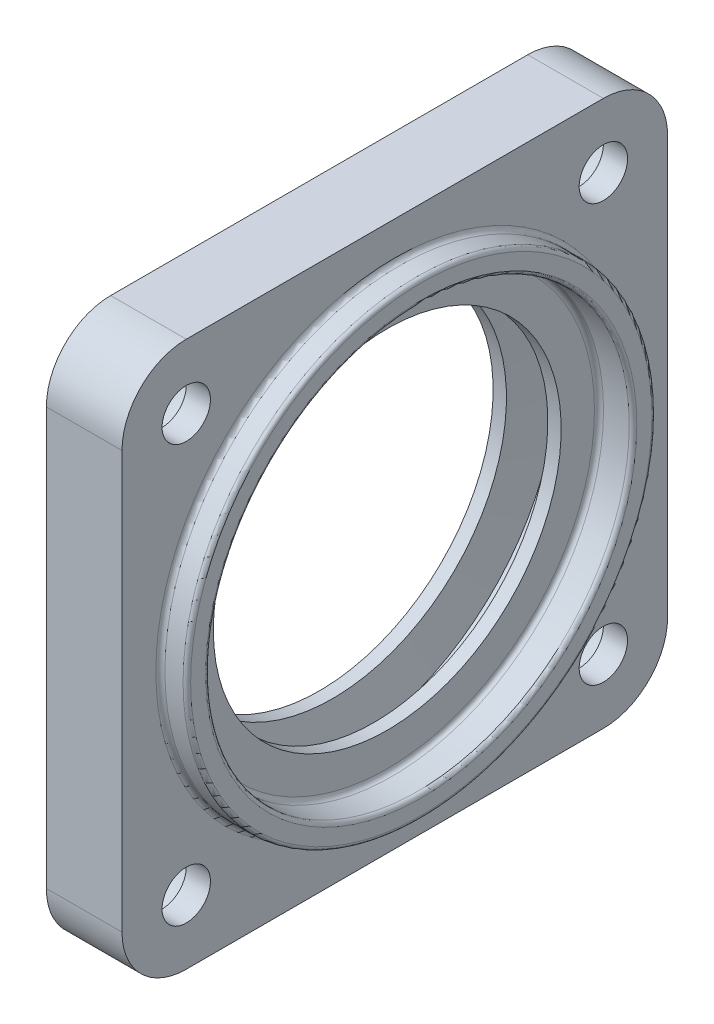
from build123d import *

# Parameters (mm, degrees)
HOLE_WIZARD_M61_D           = 6.4
HOLE_WIZARD_M61_CBORE_D     = 11
HOLE_WIZARD_M61_CBORE_DEPTH = 6.8
SKETCH_4_OUTSIDE_W          = 124.038
SKETCH_4_OUTSIDE_H          = 124.038
CUT_EXTRUDE_1_DEPTH         = 16
SKETCH_5_R                  = 31
CUT_EXTRUDE_2_DEPTH         = 1.5
FILLET_1_R                  = 0.6
FILLET_2_R                  = 0.5
FILLET_3_R                  = 0.6


with BuildPart() as part:
    # Эскиз1 → Повернуть1 (revolve)
    with BuildSketch(Plane.XY):
        Polygon((-4.5, 23), (-2.736707365, 23), (-2, 29), (2, 29), (2.736707365, 23), (4.5, 23), (4.5, 28), (10.5, 28), (10.5, 31), (5.5, 31), (5.5, 47.5), (-4.5, 47.5), align=None)
    revolve(axis=Axis((0, 0, 0), (1, 0, 0)))

    # Цековка для  болта с шестигранной головкой M61 (through all)
    with Locations(Plane(origin=(-4.5, 27.577164466, -27.577164466), x_dir=(0, 0, -1), z_dir=(-1, 0, 0))):
        with Locations((0, 0), (-55.154328932, 0), (-55.154328932, 55.154328932), (0, 55.154328932)):
            CounterBoreHole(HOLE_WIZARD_M61_D / 2, HOLE_WIZARD_M61_CBORE_D / 2, HOLE_WIZARD_M61_CBORE_DEPTH)

    # Эскиз4 outside → Вытянуть1 (cut, through all)
    with BuildSketch(Plane.ZY.offset(4.5)):
        Rectangle(SKETCH_4_OUTSIDE_W, SKETCH_4_OUTSIDE_H)
        with BuildLine():
            Line((-36.077164466, 27.577164466), (-36.077164466, -27.577164466))
            ThreePointArc((-36.077164466, -27.577164466), (-33.587572106, -33.587572106), (-27.577164466, -36.077164466))
            Line((-27.577164466, -36.077164466), (27.577164466, -36.077164466))
            ThreePointArc((27.577164466, -36.077164466), (33.587572106, -33.587572106), (36.077164466, -27.577164466))
            Line((36.077164466, -27.577164466), (36.077164466, 27.577164466))
            ThreePointArc((36.077164466, 27.577164466), (33.587572106, 33.587572106), (27.577164466, 36.077164466))
            Line((27.577164466, 36.077164466), (-27.577164466, 36.077164466))
            ThreePointArc((-27.577164466, 36.077164466), (-33.587572106, 33.587572106), (-36.077164466, 27.577164466))
        make_face(mode=Mode.SUBTRACT)
    extrude(amount=-CUT_EXTRUDE_1_DEPTH, mode=Mode.SUBTRACT)

    # Эскиз5 → Вытянуть2 (cut)
    with BuildSketch(Plane(origin=(10.5, 0, 0), x_dir=(0, 0, -1), z_dir=(1, 0, 0))):
        Circle(SKETCH_5_R)
    extrude(amount=-CUT_EXTRUDE_2_DEPTH, mode=Mode.SUBTRACT)

    # Скругление1
    fillet_1_edges = [part.edges().sort_by_distance(p)[0] for p in [
        (5.5, -31, 0),
    ]]
    fillet(fillet_1_edges, radius=FILLET_1_R)

    # Скругление2
    fillet_2_edges = [part.edges().sort_by_distance(p)[0] for p in [
        (9, -31, 0),
        (9, -28, 0),
    ]]
    fillet(fillet_2_edges, radius=FILLET_2_R)

    # Скругление3
    fillet_3_edges = [part.edges().sort_by_distance(p)[0] for p in [
        (4.5, -28, 0),
    ]]
    fillet(fillet_3_edges, radius=FILLET_3_R)


solid = part.part
